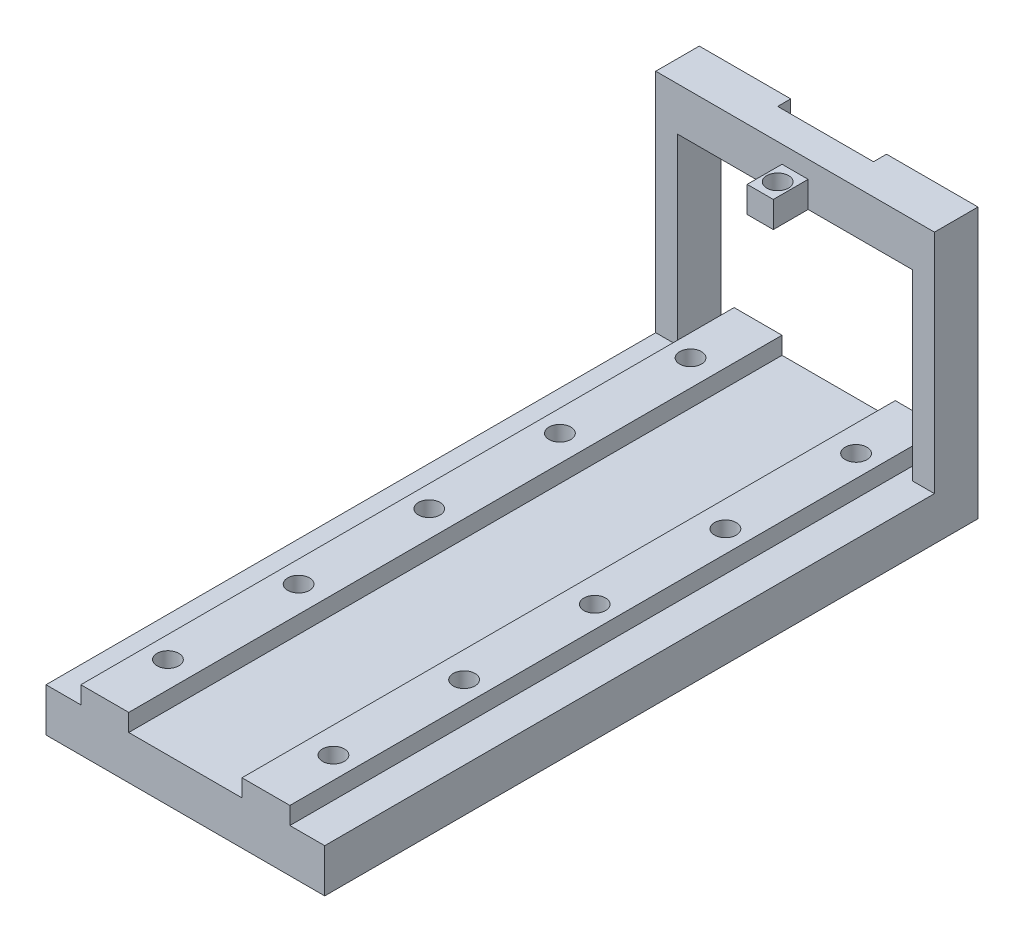
from build123d import *

# Parameters (mm, degrees)
SKETCH1_W                   = 32
SKETCH1_H                   = 75
BOSS_EXTRUDE1_DEPTH         = 5
SKETCH5_W                   = 2.5
SKETCH5_H                   = 5
BOSS_EXTRUDE2_DEPTH         = 26
SKETCH7_W                   = 5
SKETCH7_H                   = 5
BOSS_EXTRUDE3_DEPTH         = 27
SKETCH8_W                   = 11
SKETCH8_H                   = 5
CUT_EXTRUDE1_DEPTH          = 1.5
SKETCH9_W                   = 3
SKETCH9_H                   = 3
BOSS_EXTRUDE4_DEPTH         = 4
SKETCH10_R                  = 1.25
CUT_EXTRUDE2_DEPTH          = 3
SKETCH11_W                  = 5.5
SKETCH11_H                  = 75
BOSS_EXTRUDE5_DEPTH         = 2
TAP_DRILL_FOR_M3X0_5_TAP1_D = 2.5


with BuildPart() as part:
    # Sketch1 → Boss-Extrude1 (new body)
    with BuildSketch(Plane(origin=(0, 0, 0), x_dir=(1, 0, 0), z_dir=(0, 1, 0))):
        with Locations((2.576120431, -29.854896849)):
            Rectangle(SKETCH1_W, SKETCH1_H)
    extrude(amount=BOSS_EXTRUDE1_DEPTH)

    # Sketch5 → Boss-Extrude2 (add)
    with BuildSketch(Plane(origin=(0, 5, 0), x_dir=(1, 0, 0), z_dir=(0, 1, 0))):
        with Locations((-12.173879569, 5.145103151)):
            Rectangle(SKETCH5_W, SKETCH5_H)
        with Locations((17.326120431, 5.145103151)):
            Rectangle(SKETCH5_W, SKETCH5_H)
    extrude(amount=BOSS_EXTRUDE2_DEPTH)

    # Sketch7 → Boss-Extrude3 (add)
    with BuildSketch(Plane.ZY.offset(-16.076120431)):
        with Locations((-5.145103151, 28.5)):
            Rectangle(SKETCH7_W, SKETCH7_H)
    extrude(amount=BOSS_EXTRUDE3_DEPTH)

    # Sketch8 → Cut-Extrude1 (cut)
    with BuildSketch(Plane(origin=(0, 0, -7.645103151), x_dir=(-1, 0, 0), z_dir=(0, 0, -1))):
        with Locations((-2.576120431, 28.5)):
            Rectangle(SKETCH8_W, SKETCH8_H)
    extrude(amount=-CUT_EXTRUDE1_DEPTH, mode=Mode.SUBTRACT)

    # Sketch9 → Boss-Extrude4 (add)
    with BuildSketch(Plane.XY.offset(-2.645103151)):
        with Locations((2.576120431, 27.5)):
            Rectangle(SKETCH9_W, SKETCH9_H)
    extrude(amount=BOSS_EXTRUDE4_DEPTH)

    # Sketch10 → Cut-Extrude2 (cut)
    with BuildSketch(Plane(origin=(0, 26, 0), x_dir=(-1, 0, 0), z_dir=(0, -1, 0))):
        with Locations((-2.576120431, 0.645103151)):
            Circle(SKETCH10_R)
    extrude(amount=-CUT_EXTRUDE2_DEPTH, mode=Mode.SUBTRACT)

    # Sketch11 → Boss-Extrude5 (add)
    with BuildSketch(Plane(origin=(0, 5, 0), x_dir=(1, 0, 0), z_dir=(0, 1, 0))):
        with Locations((-6.673879569, -29.854896849)):
            Rectangle(SKETCH11_W, SKETCH11_H)
        with Locations((11.826120431, -29.854896849)):
            Rectangle(SKETCH11_W, SKETCH11_H)
    extrude(amount=BOSS_EXTRUDE5_DEPTH)

    # Tap Drill for M3x0.5 Tap1 (through all)
    with Locations(Plane(origin=(12.076120431, 0, 59.854896849), x_dir=(0, 0, -1), z_dir=(0, -1, 0))):
        with Locations((0, 0), (15, 0), (30, 0), (45, 0), (60, 0), (0, -19), (15, -19), (30, -19), (45, -19), (60, -19)):
            Hole(TAP_DRILL_FOR_M3X0_5_TAP1_D / 2)


solid = part.part
